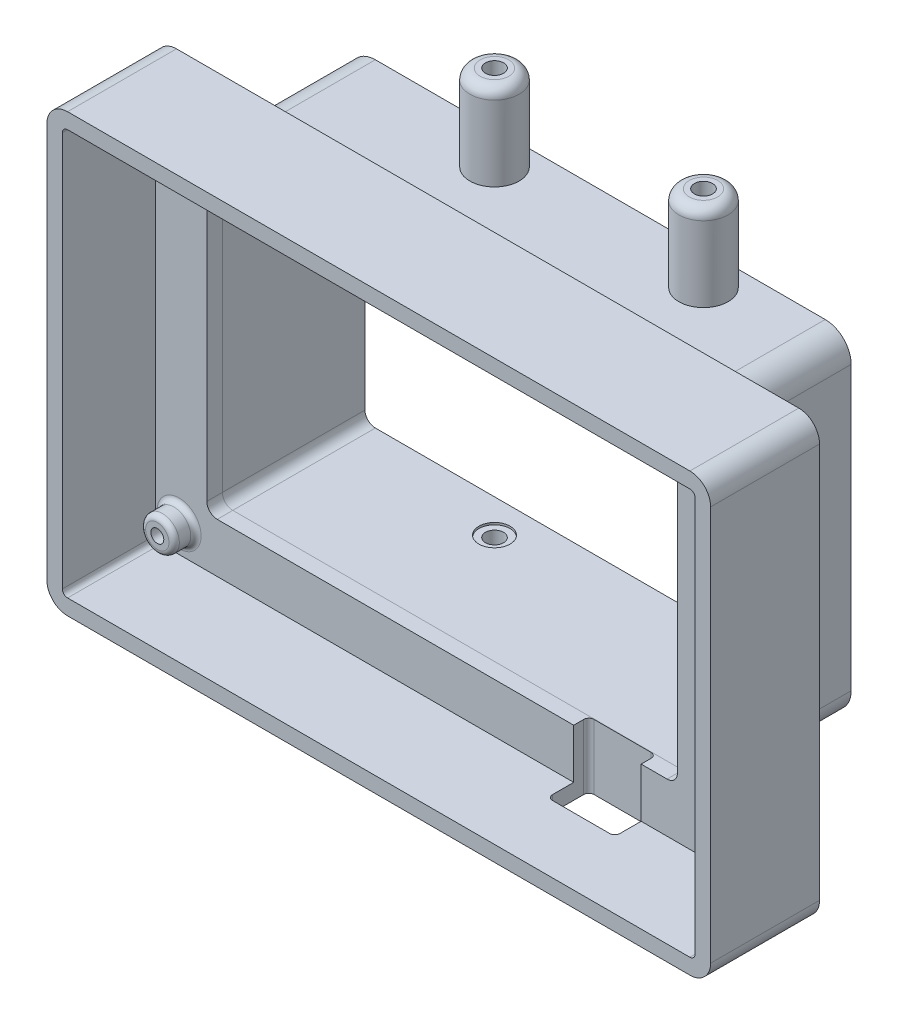
from build123d import *

# Parameters (mm, degrees)
ESQUISSE1_W                         = 122
ESQUISSE1_H                         = 78.2
ESQUISSE1_R                         = 3.25
BOSS_EXTRU_1_DEPTH                  = 18
COQUE1_T                            = 3
ENL_V_MAT_EXTRU_1_REACH             = 80.692
ESQUISSE1_3_R                       = 1.25
ENL_V_MAT_EXTRU_1_DIRECTION_2_REACH = 80.692
ESQUISSE2_R                         = 3.25
ENL_V_MAT_EXTRU_2_DEPTH             = 13.8
ESQUISSE3_W                         = 90.75
ESQUISSE3_H                         = 58.5
BOSS_EXTRU_2_DEPTH                  = 24.5
ENL_V_MAT_EXTRU_3_REACH             = 82.428
ESQUISSE3_2_W                       = 90.75
ESQUISSE3_2_H                       = 58.5
COQUE2_T                            = 3
ESQUISSE3_3_W                       = 90.75
ESQUISSE3_3_H                       = 58.5
ENL_V_MAT_EXTRU_5_DEPTH             = 27.5
CONG_1_R                            = 1
CONG_2_R                            = 4
CONG_3_R                            = 2
CONG_4_R                            = 2
CONG_5_R                            = 5
CHANFREIN1_SIZE                     = 1
ESQUISSE4_R                         = 1.75
ENL_V_MAT_EXTRU_8_DEPTH             = 3
ESQUISSE6_R                         = 3
ENL_V_MAT_EXTRU_9_DEPTH             = 1
ESQUISSE4_5_R                       = 4.75
ESQUISSE4_5_R_2                     = 1.75
BOSS_EXTRU_4_DEPTH                  = 16.5
ESQUISSE8_R                         = 4.75
BOSS_EXTRU_5_DEPTH                  = 19
ESQUISSE9_R                         = 1.75
ENL_V_MAT_EXTRU_10_DEPTH            = 19.6
CONG_6_R                            = 2
ENL_V_START                         = -12.55
ENL_V_MAT_EXTRU_11_DEPTH            = 12.55


with BuildPart() as part:
    # Esquisse1 → Boss.-Extru.1 (new body)
    with BuildSketch(Plane.XY):
        Rectangle(ESQUISSE1_W, ESQUISSE1_H)
        with Locations((-56.5, -33.9)):
            Circle(ESQUISSE1_R, mode=Mode.SUBTRACT)
        with Locations((-56.5, 33.9)):
            Circle(ESQUISSE1_R, mode=Mode.SUBTRACT)
        with Locations((56.5, -33.9)):
            Circle(ESQUISSE1_R, mode=Mode.SUBTRACT)
        with Locations((56.5, 33.9)):
            Circle(ESQUISSE1_R, mode=Mode.SUBTRACT)
    extrude(amount=BOSS_EXTRU_1_DEPTH)

    # Coque1
    coque1_openings = [part.faces().sort_by_distance(p)[0] for p in [
        (0, 0, 18),
    ]]
    offset(amount=COQUE1_T, openings=coque1_openings, kind=Kind.INTERSECTION)

    # Esquisse1_3 → Enl_v. mat.-Extru.1 (cut, up to next)
    with BuildSketch(Plane.XY, mode=Mode.PRIVATE) as enl_v_mat_extru_1_sk1:
        with Locations((-56.5, -33.9)):
            Circle(ESQUISSE1_3_R)
    enl_v_mat_extru_1_tool1 = extrude(enl_v_mat_extru_1_sk1.sketch, amount=ENL_V_MAT_EXTRU_1_REACH, mode=Mode.PRIVATE) & part.part
    # Esquisse1_3 → Enl_v. mat.-Extru.1 (cut, up to next)
    with BuildSketch(Plane.XY, mode=Mode.PRIVATE) as enl_v_mat_extru_1_sk2:
        with Locations((56.5, -33.9)):
            Circle(ESQUISSE1_3_R)
    enl_v_mat_extru_1_tool2 = extrude(enl_v_mat_extru_1_sk2.sketch, amount=ENL_V_MAT_EXTRU_1_REACH, mode=Mode.PRIVATE) & part.part
    # Esquisse1_3 → Enl_v. mat.-Extru.1 (cut, up to next)
    with BuildSketch(Plane.XY, mode=Mode.PRIVATE) as enl_v_mat_extru_1_sk3:
        with Locations((56.5, 33.9)):
            Circle(ESQUISSE1_3_R)
    enl_v_mat_extru_1_tool3 = extrude(enl_v_mat_extru_1_sk3.sketch, amount=ENL_V_MAT_EXTRU_1_REACH, mode=Mode.PRIVATE) & part.part
    # Esquisse1_3 → Enl_v. mat.-Extru.1 (cut, up to next)
    with BuildSketch(Plane.XY, mode=Mode.PRIVATE) as enl_v_mat_extru_1_sk4:
        with Locations((-56.5, 33.9)):
            Circle(ESQUISSE1_3_R)
    enl_v_mat_extru_1_tool4 = extrude(enl_v_mat_extru_1_sk4.sketch, amount=ENL_V_MAT_EXTRU_1_REACH, mode=Mode.PRIVATE) & part.part
    add(enl_v_mat_extru_1_tool1.solids().sort_by_distance((-56.5, -33.9, 0))[0], mode=Mode.SUBTRACT)
    add(enl_v_mat_extru_1_tool2.solids().sort_by_distance((56.5, -33.9, 0))[0], mode=Mode.SUBTRACT)
    add(enl_v_mat_extru_1_tool3.solids().sort_by_distance((56.5, 33.9, 0))[0], mode=Mode.SUBTRACT)
    add(enl_v_mat_extru_1_tool4.solids().sort_by_distance((-56.5, 33.9, 0))[0], mode=Mode.SUBTRACT)

    # Esquisse1_3 → Enl_v. mat.-Extru.1 direction 2 (cut, up to next)
    with BuildSketch(Plane.XY, mode=Mode.PRIVATE) as enl_v_mat_extru_1_direction_2_sk1:
        with Locations((-56.5, -33.9)):
            Circle(ESQUISSE1_3_R)
    enl_v_mat_extru_1_direction_2_tool1 = extrude(enl_v_mat_extru_1_direction_2_sk1.sketch, amount=-ENL_V_MAT_EXTRU_1_DIRECTION_2_REACH, mode=Mode.PRIVATE) & part.part
    # Esquisse1_3 → Enl_v. mat.-Extru.1 direction 2 (cut, up to next)
    with BuildSketch(Plane.XY, mode=Mode.PRIVATE) as enl_v_mat_extru_1_direction_2_sk2:
        with Locations((56.5, -33.9)):
            Circle(ESQUISSE1_3_R)
    enl_v_mat_extru_1_direction_2_tool2 = extrude(enl_v_mat_extru_1_direction_2_sk2.sketch, amount=-ENL_V_MAT_EXTRU_1_DIRECTION_2_REACH, mode=Mode.PRIVATE) & part.part
    # Esquisse1_3 → Enl_v. mat.-Extru.1 direction 2 (cut, up to next)
    with BuildSketch(Plane.XY, mode=Mode.PRIVATE) as enl_v_mat_extru_1_direction_2_sk3:
        with Locations((56.5, 33.9)):
            Circle(ESQUISSE1_3_R)
    enl_v_mat_extru_1_direction_2_tool3 = extrude(enl_v_mat_extru_1_direction_2_sk3.sketch, amount=-ENL_V_MAT_EXTRU_1_DIRECTION_2_REACH, mode=Mode.PRIVATE) & part.part
    # Esquisse1_3 → Enl_v. mat.-Extru.1 direction 2 (cut, up to next)
    with BuildSketch(Plane.XY, mode=Mode.PRIVATE) as enl_v_mat_extru_1_direction_2_sk4:
        with Locations((-56.5, 33.9)):
            Circle(ESQUISSE1_3_R)
    enl_v_mat_extru_1_direction_2_tool4 = extrude(enl_v_mat_extru_1_direction_2_sk4.sketch, amount=-ENL_V_MAT_EXTRU_1_DIRECTION_2_REACH, mode=Mode.PRIVATE) & part.part
    add(enl_v_mat_extru_1_direction_2_tool1.solids().sort_by_distance((-56.5, -33.9, 0))[0], mode=Mode.SUBTRACT)
    add(enl_v_mat_extru_1_direction_2_tool2.solids().sort_by_distance((56.5, -33.9, 0))[0], mode=Mode.SUBTRACT)
    add(enl_v_mat_extru_1_direction_2_tool3.solids().sort_by_distance((56.5, 33.9, 0))[0], mode=Mode.SUBTRACT)
    add(enl_v_mat_extru_1_direction_2_tool4.solids().sort_by_distance((-56.5, 33.9, 0))[0], mode=Mode.SUBTRACT)

    # Esquisse2 → Enl_v. mat.-Extru.2 (cut)
    with BuildSketch(Plane.XY.offset(18)):
        with Locations((-56.5, 33.9)):
            Circle(ESQUISSE2_R)
        with Locations((56.5, 33.9)):
            Circle(ESQUISSE2_R)
        with Locations((56.5, -33.9)):
            Circle(ESQUISSE2_R)
        with Locations((-56.5, -33.9)):
            Circle(ESQUISSE2_R)
    extrude(amount=-ENL_V_MAT_EXTRU_2_DEPTH, mode=Mode.SUBTRACT)

    # Esquisse3 → Boss.-Extru.2 (add)
    with BuildSketch(Plane(origin=(0, 0, -3), x_dir=(-1, 0, 0), z_dir=(0, 0, -1))):
        with Locations((5.775, -0.3)):
            Rectangle(ESQUISSE3_W, ESQUISSE3_H)
    extrude(amount=BOSS_EXTRU_2_DEPTH)

    # Esquisse3_2 → Enl_v. mat.-Extru.3 (cut, up to next)
    with BuildSketch(Plane(origin=(0, 0, -3), x_dir=(-1, 0, 0), z_dir=(0, 0, -1)), mode=Mode.PRIVATE) as enl_v_mat_extru_3_sk1:
        with Locations((5.775, -0.3)):
            Rectangle(ESQUISSE3_2_W, ESQUISSE3_2_H)
    enl_v_mat_extru_3_tool1 = extrude(enl_v_mat_extru_3_sk1.sketch, amount=-ENL_V_MAT_EXTRU_3_REACH, mode=Mode.PRIVATE) & part.part
    add(enl_v_mat_extru_3_tool1.solids().sort_by_distance((-5.775, -0.3, -3))[0], mode=Mode.SUBTRACT)


with BuildPart() as enl_v_mat_extru_3_piece_1:
    # of the separate pieces the step leaves, piece 1, a body of its own (enl_v_mat_extru_3_pieces)
    add(part.part.solids().sort_by_distance((39.6, 28.95, -27.5))[0])

    # Coque2
    coque2_openings = [enl_v_mat_extru_3_piece_1.faces().sort_by_distance(p)[0] for p in [
        (-5.775, -0.3, -3),
    ]]
    offset(amount=COQUE2_T, openings=coque2_openings, kind=Kind.INTERSECTION)

    # Esquisse3_3 → Enl_v. mat.-Extru.5 (cut)
    with BuildSketch(Plane(origin=(0, 0, -3), x_dir=(-1, 0, 0), z_dir=(0, 0, -1))):
        with Locations((5.775, -0.3)):
            Rectangle(ESQUISSE3_3_W, ESQUISSE3_3_H)
    extrude(amount=ENL_V_MAT_EXTRU_5_DEPTH, mode=Mode.SUBTRACT)

    # Cong_3
    cong_3_edges = [enl_v_mat_extru_3_piece_1.edges().sort_by_distance(p)[0] for p in [
        (-51.15, 28.95, -16.75),
        (-51.15, -29.55, -16.75),
        (39.6, -29.55, -16.75),
        (39.6, 28.95, -16.75),
    ]]
    fillet(cong_3_edges, radius=CONG_3_R)

    # Cong_5
    cong_5_edges = [enl_v_mat_extru_3_piece_1.edges().sort_by_distance(p)[0] for p in [
        (42.6, 31.95, -16.75),
        (42.6, -32.55, -16.75),
        (-54.15, -32.55, -16.75),
        (-54.15, 31.95, -16.75),
    ]]
    fillet(cong_5_edges, radius=CONG_5_R)

    # Esquisse4 → Enl_v. mat.-Extru.8 (cut)
    with BuildSketch(Plane(origin=(0, 31.95, 0), x_dir=(1, 0, 0), z_dir=(0, 1, 0))):
        with Locations(Location((-19.775, 24.1, 0), (0, 0, 270))):
            Circle(ESQUISSE4_R)
        with Locations(Location((20.525, 24.1, 0), (0, 0, 270))):
            Circle(ESQUISSE4_R)
    enl_v_mat_extru_8 = extrude(amount=-ENL_V_MAT_EXTRU_8_DEPTH, mode=Mode.SUBTRACT)

    # Esquisse6 → Enl_v. mat.-Extru.9 (cut)
    with BuildSketch(Plane.XZ.offset(-28.95)):
        with Locations(Location((-19.775, -24.1, 0), (0, 0, 270))):
            Circle(ESQUISSE6_R)
        with Locations(Location((20.525, -24.1, 0), (0, 0, 270))):
            Circle(ESQUISSE6_R)
    enl_v_mat_extru_9 = extrude(amount=-ENL_V_MAT_EXTRU_9_DEPTH, mode=Mode.SUBTRACT)

    # Esquisse4_5 → Boss.-Extru.4 (add)
    with BuildSketch(Plane(origin=(0, 31.95, 0), x_dir=(1, 0, 0), z_dir=(0, 1, 0))):
        with Locations(Location((-19.775, 24.1, 0), (0, 0, 90))):
            Circle(ESQUISSE4_5_R)
        with Locations(Location((-19.775, 24.1, 0), (0, 0, 270))):
            Circle(ESQUISSE4_5_R_2, mode=Mode.SUBTRACT)
        with Locations(Location((20.525, 24.1, 0), (0, 0, 90))):
            Circle(ESQUISSE4_5_R)
        with Locations(Location((20.525, 24.1, 0), (0, 0, 270))):
            Circle(ESQUISSE4_5_R_2, mode=Mode.SUBTRACT)
    boss_extru_4 = extrude(amount=BOSS_EXTRU_4_DEPTH)

    # Sym_trie1: Enl_v. mat.-Extru.8, Enl_v. mat.-Extru.9, Boss.-Extru.4 across plane
    add(enl_v_mat_extru_8.mirror(Plane.ZX), mode=Mode.SUBTRACT)
    add(enl_v_mat_extru_9.mirror(Plane.ZX), mode=Mode.SUBTRACT)
    add(boss_extru_4.mirror(Plane.ZX))

    # Esquisse8 → Boss.-Extru.5 (add)
    with BuildSketch(Plane.XZ.offset(32.55)):
        with Locations(Location((-19.775, -24.1, 0), (0, 0, 270))):
            Circle(ESQUISSE8_R)
        with Locations(Location((20.525, -24.1, 0), (0, 0, 270))):
            Circle(ESQUISSE8_R)
    extrude(amount=BOSS_EXTRU_5_DEPTH)

    # Esquisse9 → Enl_v. mat.-Extru.10 (cut)
    with BuildSketch(Plane.XZ.offset(51.55)):
        with Locations(Location((20.525, -24.1, 0), (0, 0, 90))):
            Circle(ESQUISSE9_R)
        with Locations(Location((-19.775, -24.1, 0), (0, 0, 90))):
            Circle(ESQUISSE9_R)
    extrude(amount=-ENL_V_MAT_EXTRU_10_DEPTH, mode=Mode.SUBTRACT)

    # Cong_6
    cong_6_edges = [enl_v_mat_extru_3_piece_1.edges().sort_by_distance(p)[0] for p in [
        (-19.775, 48.45, -19.35),
        (20.525, 48.45, -19.35),
        (-19.775, -51.55, -19.35),
        (20.525, -51.55, -19.35),
    ]]
    fillet(cong_6_edges, radius=CONG_6_R)


with BuildPart() as enl_v_mat_extru_3_piece_2:
    # of the separate pieces the step leaves, piece 2, a body of its own (enl_v_mat_extru_3_pieces)
    add(part.part.solids().sort_by_distance((61, 39.1, 0))[0])

    # Cong_1
    cong_1_edges = [enl_v_mat_extru_3_piece_2.edges().sort_by_distance(p)[0] for p in [
        (53.25, -33.9, 0),
        (-59.75, 33.9, 0),
        (61, 39.1, 9),
        (-61, 39.1, 9),
        (-61, -39.1, 9),
        (61, -39.1, 9),
        (-59.75, -33.9, 0),
        (53.25, 33.9, 0),
        (-59.75, 33.9, 4.2),
        (53.25, 33.9, 4.2),
        (53.25, -33.9, 4.2),
        (-59.75, -33.9, 4.2),
    ]]
    fillet(cong_1_edges, radius=CONG_1_R)

    # Cong_2
    cong_2_edges = [enl_v_mat_extru_3_piece_2.edges().sort_by_distance(p)[0] for p in [
        (64, -42.1, 7.5),
        (64, 42.1, 7.5),
        (-64, 42.1, 7.5),
        (-64, -42.1, 7.5),
    ]]
    fillet(cong_2_edges, radius=CONG_2_R)

    # Cong_4
    cong_4_edges = [enl_v_mat_extru_3_piece_2.edges().sort_by_distance(p)[0] for p in [
        (39.6, 28.95, -1.5),
        (-51.15, 28.95, -1.5),
        (-51.15, -29.55, -1.5),
        (39.6, -29.55, -1.5),
    ]]
    fillet(cong_4_edges, radius=CONG_4_R)

    # Chanfrein1
    chanfrein1_edges = [enl_v_mat_extru_3_piece_2.edges().sort_by_distance(p)[0] for p in [
        (55.25, 33.9, -3),
        (-57.75, -33.9, -3),
        (55.25, -33.9, -3),
        (-57.75, 33.9, -3),
    ]]
    chamfer(chanfrein1_edges, length=CHANFREIN1_SIZE)

    # Esquisse10 → Enl_v. mat.-Extru.11 (cut)
    with BuildSketch(Plane.XZ.offset(42.1).offset(ENL_V_START)):
        with BuildLine():
            Line((20.6, 5.075), (31.6, 5.075))
            ThreePointArc((31.6, 5.075), (32.307106781, 4.782106781), (32.6, 4.075))
            Line((32.6, 4.075), (32.6, -1.925))
            ThreePointArc((32.6, -1.925), (32.307106781, -2.632106781), (31.6, -2.925))
            Line((31.6, -2.925), (20.6, -2.925))
            ThreePointArc((20.6, -2.925), (19.892893219, -2.632106781), (19.6, -1.925))
            Line((19.6, -1.925), (19.6, 4.075))
            ThreePointArc((19.6, 4.075), (19.892893219, 4.782106781), (20.6, 5.075))
        make_face()
    extrude(amount=ENL_V_MAT_EXTRU_11_DEPTH, mode=Mode.SUBTRACT)


solid = Compound([enl_v_mat_extru_3_piece_1.part, enl_v_mat_extru_3_piece_2.part])
